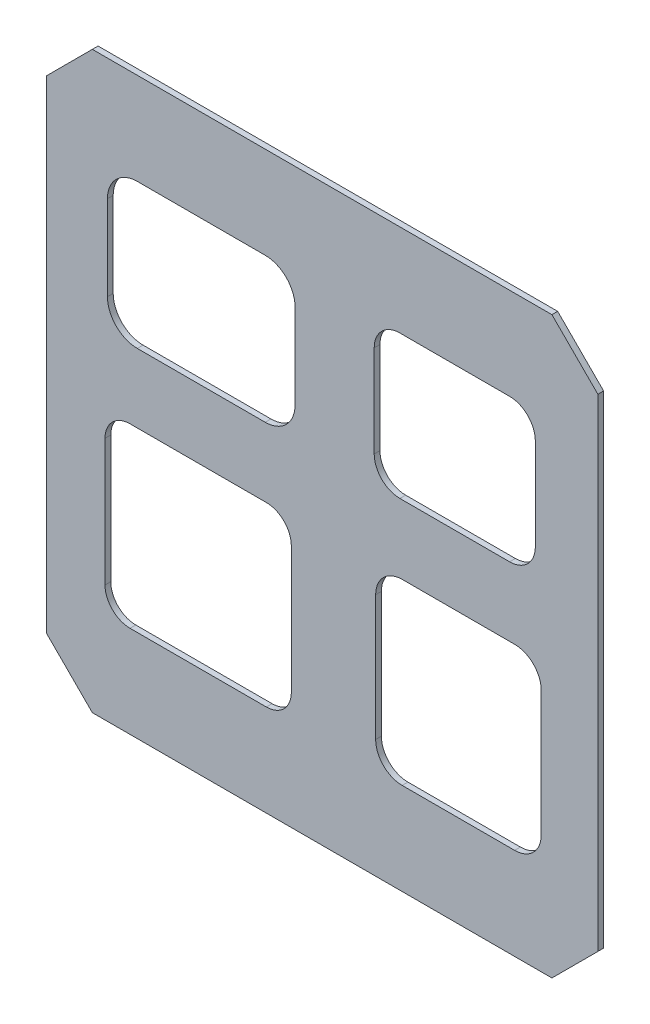
from build123d import *

# Parameters (mm, degrees)
BOSS_EXTRUDE1_DEPTH = 3.175
CUT_EXTRUDE7_DEPTH  = 127


with BuildPart() as part:
    # Sketch1 → Boss-Extrude1 (new body)
    with BuildSketch(Plane.XY):
        Polygon((0, 266.7), (25.4, 292.1), (279.4, 292.1), (304.8, 266.7), (304.8, 0), (279.4, -25.4), (25.4, -25.4), (0, 0), align=None)
    extrude(amount=BOSS_EXTRUDE1_DEPTH)

    # Sketch4 → Cut-Extrude7 (cut)
    with BuildSketch(Plane.XY.offset(3.175)):
        with BuildLine():
            Line((50.258895016, 241.3), (120.933418015, 241.3))
            ThreePointArc((120.933418015, 241.3), (132.607750972, 236.464332957), (137.443418015, 224.79))
            Line((137.443418015, 224.79), (137.443418015, 177.875697945))
            ThreePointArc((137.443418015, 177.875697945), (132.607750972, 166.201364987), (120.933418015, 161.365697945))
            Line((120.933418015, 161.365697945), (50.258895016, 161.365697945))
            ThreePointArc((50.258895016, 161.365697945), (38.584562059, 166.201364987), (33.748895016, 177.875697945))
            Line((33.748895016, 177.875697945), (33.748895016, 224.79))
            ThreePointArc((33.748895016, 224.79), (38.584562059, 236.464332957), (50.258895016, 241.3))
        make_face()
        with BuildLine():
            Line((195.366803118, 241.3), (256.035491463, 241.3))
            ThreePointArc((256.035491463, 241.3), (266.070381863, 237.143412299), (270.226969564, 227.108521899))
            Line((270.226969564, 227.108521899), (270.226969564, 176.308521899))
            ThreePointArc((270.226969564, 176.308521899), (266.070381863, 166.273631498), (256.035491463, 162.117043797))
            Line((256.035491463, 162.117043797), (195.366803118, 162.117043797))
            ThreePointArc((195.366803118, 162.117043797), (185.331912718, 166.273631498), (181.175325017, 176.308521899))
            Line((181.175325017, 176.308521899), (181.175325017, 227.108521899))
            ThreePointArc((181.175325017, 227.108521899), (185.331912718, 237.143412299), (195.366803118, 241.3))
        make_face()
        with BuildLine():
            Line((121.145780521, 123.265697945), (46.236873468, 123.265697945))
            ThreePointArc((46.236873468, 123.265697945), (36.46177638, 119.216720157), (32.412798593, 109.44162307))
            Line((32.412798593, 109.44162307), (32.412798593, 39.224074875))
            ThreePointArc((32.412798593, 39.224074875), (36.46177638, 29.448977787), (46.236873468, 25.4))
            Line((46.236873468, 25.4), (121.551145478, 25.4))
            ThreePointArc((121.551145478, 25.4), (131.326242565, 29.448977787), (135.375220353, 39.224074875))
            Line((135.375220353, 39.224074875), (135.375220353, 109.44162307))
            ThreePointArc((135.375220353, 109.44162307), (131.183991006, 119.362876931), (121.145780521, 123.265697945))
        make_face()
        with BuildLine():
            Line((196.644821232, 124.017043797), (258.815551629, 124.017043797))
            ThreePointArc((258.815551629, 124.017043797), (269.182807745, 119.722785709), (273.477065833, 109.355529593))
            Line((273.477065833, 109.355529593), (273.477065833, 40.061514204))
            ThreePointArc((273.477065833, 40.061514204), (269.182807745, 29.694258088), (258.815551629, 25.4))
            Line((258.815551629, 25.4), (196.644821232, 25.4))
            ThreePointArc((196.644821232, 25.4), (186.277565116, 29.694258088), (181.983307028, 40.061514204))
            Line((181.983307028, 40.061514204), (181.983307028, 109.355529593))
            ThreePointArc((181.983307028, 109.355529593), (186.277565116, 119.722785709), (196.644821232, 124.017043797))
        make_face()
    extrude(amount=-CUT_EXTRUDE7_DEPTH, mode=Mode.SUBTRACT)


solid = part.part
